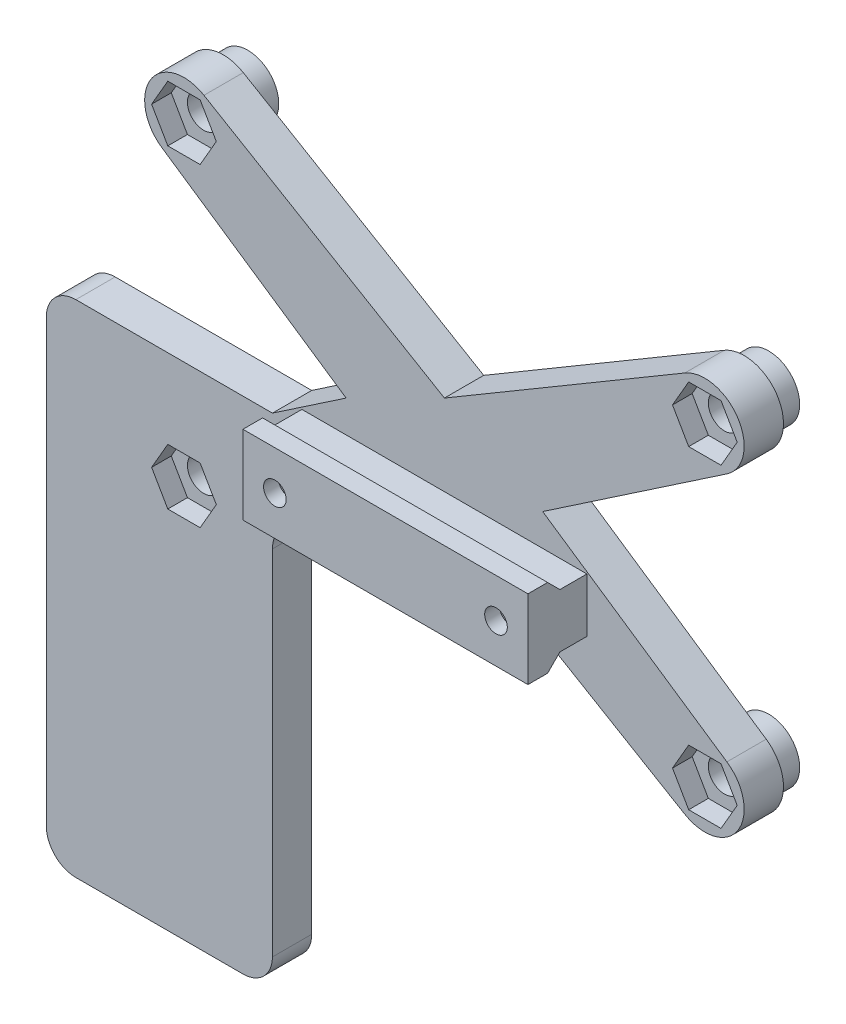
from build123d import *

# Parameters (mm, degrees)
SKETCH_1_R          = 1.65
EXTRUDE_1_DEPTH     = 4
CUT_EXTRUDE_1_DEPTH = 2
SKETCH_5_R          = 3.15
SKETCH_5_R_2        = 1.65
EXTRUDE_3_DEPTH     = 2.5
EXTRUDE_2_DEPTH     = 14.5
SKETCH_4_R          = 1.15
CUT_EXTRUDE_2_DEPTH = 13.5
CUT_EXTRUDE_3_DEPTH = 8.5
EXTRUDE_4_DEPTH     = 4
FILLET_1_R          = 3


with BuildPart() as part:
    # 草图1 → 凸台-拉伸1 (new body)
    with BuildSketch(Plane.XY):
        with BuildLine():
            Line((-24.466432563, 19.444503372), (0, 5))
            Line((0, 5), (24.466432563, 19.444503372))
            ThreePointArc((24.466432563, 19.444503372), (29.880062562, 18.138966358), (28.742325032, 12.687602311))
            Line((28.742325032, 12.687602311), (10, 0))
            Line((10, 0), (28.742325032, -12.687602311))
            ThreePointArc((28.742325032, -12.687602311), (29.880062562, -18.138966358), (24.466432563, -19.444503372))
            Line((24.466432563, -19.444503372), (0, -5))
            Line((0, -5), (-24.466432563, -19.444503372))
            ThreePointArc((-24.466432563, -19.444503372), (-29.880062562, -18.138966358), (-28.742325032, -12.687602311))
            Line((-28.742325032, -12.687602311), (-10, 0))
            Line((-10, 0), (-28.742325032, 12.687602311))
            ThreePointArc((-28.742325032, 12.687602311), (-29.880062562, 18.138966358), (-24.466432563, 19.444503372))
        make_face()
        with Locations((-26.5, 16)):
            Circle(SKETCH_1_R, mode=Mode.SUBTRACT)
        with Locations((26.5, 16)):
            Circle(SKETCH_1_R, mode=Mode.SUBTRACT)
        with Locations((26.5, -16)):
            Circle(SKETCH_1_R, mode=Mode.SUBTRACT)
        with Locations((-26.5, -16)):
            Circle(SKETCH_1_R, mode=Mode.SUBTRACT)
    extrude(amount=EXTRUDE_1_DEPTH)

    # 草图2 → 切除-拉伸1 (cut)
    with BuildSketch(Plane.XY.offset(4)):
        Polygon((-24.854551733, 18.85), (-28.145448267, 18.85), (-29.790896534, 16), (-28.145448267, 13.15), (-24.854551733, 13.15), (-23.209103466, 16), align=None)
        Polygon((28.145448267, 18.85), (24.854551733, 18.85), (23.209103466, 16), (24.854551733, 13.15), (28.145448267, 13.15), (29.790896534, 16), align=None)
        Polygon((28.145448267, -13.15), (24.854551733, -13.15), (23.209103466, -16), (24.854551733, -18.85), (28.145448267, -18.85), (29.790896534, -16), align=None)
        Polygon((-24.854551733, -13.15), (-28.145448267, -13.15), (-29.790896534, -16), (-28.145448267, -18.85), (-24.854551733, -18.85), (-23.209103466, -16), align=None)
    extrude(amount=-CUT_EXTRUDE_1_DEPTH, mode=Mode.SUBTRACT)

    # 草图5 → 凸台-拉伸3 (add)
    with BuildSketch(Plane(origin=(0, 0, 0), x_dir=(-1, 0, 0), z_dir=(0, 0, -1))):
        with Locations((26.5, 16)):
            Circle(SKETCH_5_R)
        with Locations((26.5, 16)):
            Circle(SKETCH_5_R_2, mode=Mode.SUBTRACT)
        with Locations((26.5, -16)):
            Circle(SKETCH_5_R)
        with Locations((26.5, -16)):
            Circle(SKETCH_5_R_2, mode=Mode.SUBTRACT)
        with Locations((-26.5, -16)):
            Circle(SKETCH_5_R)
        with Locations((-26.5, -16)):
            Circle(SKETCH_5_R_2, mode=Mode.SUBTRACT)
        with Locations((-26.5, 16)):
            Circle(SKETCH_5_R)
        with Locations((-26.5, 16)):
            Circle(SKETCH_5_R_2, mode=Mode.SUBTRACT)
    extrude(amount=EXTRUDE_3_DEPTH)

    # 草图3 → 凸台-拉伸2 (add, symmetric)
    with BuildSketch(Plane(origin=(0, 0, 0), x_dir=(0, 0, -1), z_dir=(1, 0, 0))):
        Polygon((0, -8.75), (0, -3.25), (-6.75, -3.25), (-8, -2), (-10, -2), (-10, -10), (-8, -10), (-6.75, -8.75), align=None)
    extrude(amount=EXTRUDE_2_DEPTH, both=True)

    # 草图4 → 切除-拉伸2 (cut, through all)
    with BuildSketch(Plane.XY.offset(10)):
        with Locations((-11.25, -6)):
            Circle(SKETCH_4_R)
        with Locations((11.25, -6)):
            Circle(SKETCH_4_R)
    extrude(amount=-CUT_EXTRUDE_2_DEPTH, mode=Mode.SUBTRACT)

    # 草图6 → 切除-拉伸3 (cut)
    with BuildSketch(Plane(origin=(0, 0, 0), x_dir=(-1, 0, 0), z_dir=(0, 0, -1))):
        Polygon((-10.066431948, -3.95), (-12.433568052, -3.95), (-13.617136104, -6), (-12.433568052, -8.05), (-10.066431948, -8.05), (-8.882863896, -6), align=None)
        Polygon((12.433568052, -3.95), (10.066431948, -3.95), (8.882863896, -6), (10.066431948, -8.05), (12.433568052, -8.05), (13.617136104, -6), align=None)
    extrude(amount=-CUT_EXTRUDE_3_DEPTH, mode=Mode.SUBTRACT)

    # 草图7 → 凸台-拉伸4 (add)
    with BuildSketch(Plane(origin=(0, 0, 0), x_dir=(-1, 0, 0), z_dir=(0, 0, -1))):
        with BuildLine():
            Line((17.5, -5.07711915), (40.5, -5.07711915))
            Line((40.5, -5.07711915), (40.5, -56))
            Line((40.5, -56), (17.5, -56))
            Line((17.5, -56), (17.5, -15.331657807))
            Line((17.5, -15.331657807), (24.466432563, -19.444503372))
            ThreePointArc((24.466432563, -19.444503372), (29.880062562, -18.138966358), (28.742325032, -12.687602311))
            Line((28.742325032, -12.687602311), (17.5, -5.07711915))
        make_face()
    extrude(amount=-EXTRUDE_4_DEPTH)

    # 圆角1
    fillet_1_edges = [part.edges().sort_by_distance(p)[0] for p in [
        (-40.5, -5.07711915, 2),
        (-40.5, -56, 2),
        (-17.5, -56, 2),
        (-17.5, -15.331657807, 2),
    ]]
    fillet(fillet_1_edges, radius=FILLET_1_R)


solid = part.part
